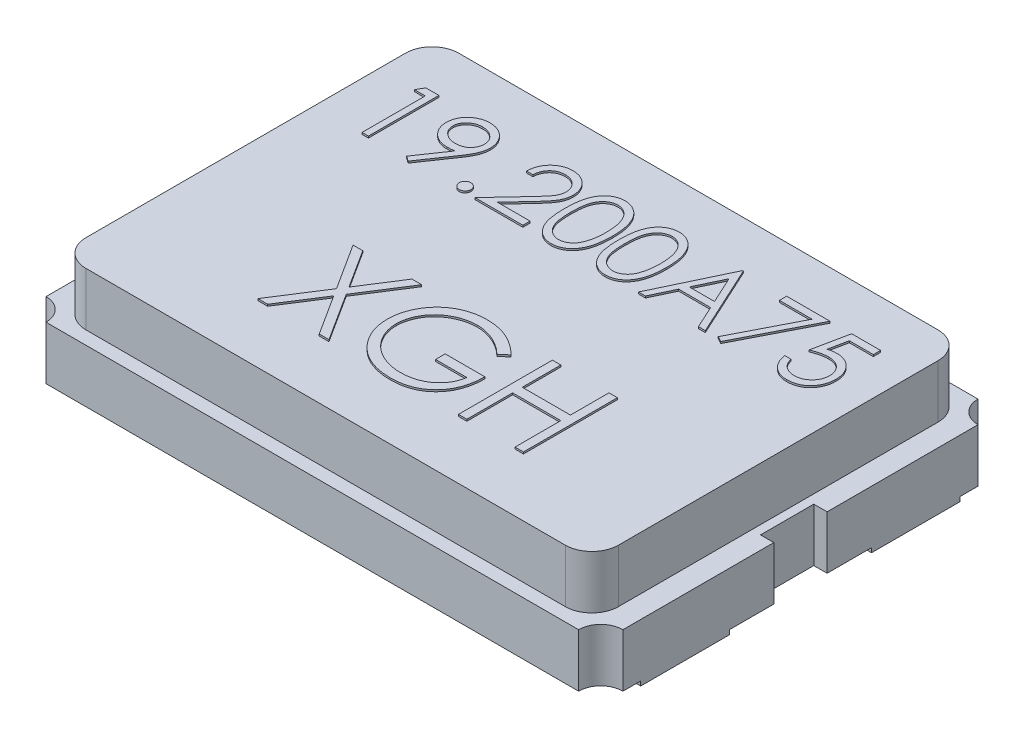
from build123d import *

# Parameters (mm, degrees)
EXTRUDE1_DEPTH = 0.6
EXTRUDE2_DEPTH = 0.6
SKETCH3_W      = 1
SKETCH3_H      = 1
EXTRUDE3_DEPTH = 0.05
EXTRUDE4_DEPTH = 0.02
EXTRUDE5_DEPTH = 0.02


with BuildPart() as part:
    # Sketch1 → Extrude1 (new body)
    with BuildSketch(Plane(origin=(0, 0, 0), x_dir=(1, 0, 0), z_dir=(0, 1, 0))):
        with BuildLine():
            Line((-3.25, 2), (-3.25, 0.3))
            Line((-3.25, 0.3), (-3.1, 0.3))
            Line((-3.1, 0.3), (-3.1, -0.3))
            Line((-3.1, -0.3), (-3.25, -0.3))
            Line((-3.25, -0.3), (-3.25, -2))
            ThreePointArc((-3.25, -2), (-3.073223305, -2.073223305), (-3, -2.25))
            Line((-3, -2.25), (3, -2.25))
            ThreePointArc((3, -2.25), (3.073223305, -2.073223305), (3.25, -2))
            Line((3.25, -2), (3.25, -0.3))
            Line((3.25, -0.3), (3.1, -0.3))
            Line((3.1, -0.3), (3.1, 0.3))
            Line((3.1, 0.3), (3.25, 0.3))
            Line((3.25, 0.3), (3.25, 2))
            ThreePointArc((3.25, 2), (3.073223305, 2.073223305), (3, 2.25))
            Line((3, 2.25), (-3, 2.25))
            ThreePointArc((-3, 2.25), (-3.073223305, 2.073223305), (-3.25, 2))
        make_face()
    extrude(amount=EXTRUDE1_DEPTH)

    # Sketch2 → Extrude2 (add)
    with BuildSketch(Plane(origin=(0, 0.6, 0), x_dir=(1, 0, 0), z_dir=(0, 1, 0))):
        with BuildLine():
            Line((-2.7, 2.1), (2.7, 2.1))
            ThreePointArc((2.7, 2.1), (2.912132034, 2.012132034), (3, 1.8))
            Line((3, 1.8), (3, -1.8))
            ThreePointArc((3, -1.8), (2.912132034, -2.012132034), (2.7, -2.1))
            Line((2.7, -2.1), (-2.7, -2.1))
            ThreePointArc((-2.7, -2.1), (-2.912132034, -2.012132034), (-3, -1.8))
            Line((-3, -1.8), (-3, 1.8))
            ThreePointArc((-3, 1.8), (-2.912132034, 2.012132034), (-2.7, 2.1))
        make_face()
    extrude(amount=EXTRUDE2_DEPTH)

    # Sketch3 → Extrude3 (add)
    with BuildSketch(Plane.XZ):
        with Locations((-2.75, 1.3)):
            Rectangle(SKETCH3_W, SKETCH3_H)
        with Locations((-2.75, -1.3)):
            Rectangle(SKETCH3_W, SKETCH3_H)
        with Locations((2.75, 1.3)):
            Rectangle(SKETCH3_W, SKETCH3_H)
        with Locations((2.75, -1.3)):
            Rectangle(SKETCH3_W, SKETCH3_H)
    extrude(amount=EXTRUDE3_DEPTH)

    # Sketch4 → Extrude4 (add)
    with BuildSketch(Plane(origin=(0, 1.2, 0), x_dir=(1, 0, 0), z_dir=(0, 1, 0))):
        Polygon((-2.526616546, 1.555911653), (-2.379855478, 1.555911653), (-2.379855478, 0.762161653), (-2.451089453, 0.762161653), (-2.451089453, 1.474501397), (-2.573204837, 1.474501397), align=None)
        with BuildLine():
            Line((-1.911746504, 0.741809089), (-1.968670082, 0.781401186))
            Line((-1.968670082, 0.781401186), (-1.747971965, 1.104021128))
            add(Edge.make_bspline(
                [(-1.747971965, 1.104021128), (-1.762053257, 1.10229913), (-1.789780105, 1.098908419), (-1.817705841, 1.098285517), (-1.831449279, 1.097978961)],
                knots=[0, 0, 0, 0, 4.2529e-05, 8.3742e-05, 8.3742e-05, 8.3742e-05, 8.3742e-05], degree=3))
            add(Edge.make_bspline(
                [(-1.831449279, 1.097978961), (-1.83978185, 1.098192384), (-1.856137959, 1.098611314), (-1.880184423, 1.101931867), (-1.903290613, 1.107045914), (-1.925395271, 1.11467697), (-1.94658148, 1.124160743), (-1.96680299, 1.135921173), (-1.986032579, 1.149756528), (-2.004063724, 1.165593653), (-2.020462993, 1.18298314), (-2.035073277, 1.20138808), (-2.047215641, 1.221022274), (-2.057302295, 1.241485199), (-2.06495188, 1.263070969), (-2.070522313, 1.285533958), (-2.073951847, 1.309031598), (-2.074359856, 1.32502569), (-2.074567017, 1.333146479)],
                knots=[0, 0, 0, 0, 2.4988e-05, 4.905e-05, 7.2695e-05, 9.5876e-05, 0.000119076, 0.00014223, 0.000165926, 0.000190038, 0.000214108, 0.000237551, 0.000260406, 0.000283233, 0.000305865, 0.000328965, 0.000352576, 0.000376929, 0.000376929, 0.000376929, 0.000376929], degree=3))
            add(Edge.make_bspline(
                [(-2.074567017, 1.333146479), (-2.074173672, 1.34425187), (-2.073401615, 1.366049499), (-2.067188023, 1.397897872), (-2.056968982, 1.428011963), (-2.042720404, 1.456312596), (-2.024773779, 1.482392668), (-2.00320451, 1.50588962), (-1.978143789, 1.526469256), (-1.95016251, 1.544159467), (-1.91991995, 1.558386868), (-1.888245093, 1.568873281), (-1.855380641, 1.575041568), (-1.833117616, 1.57585479), (-1.821909014, 1.576264217)],
                knots=[0, 0, 0, 0, 3.3296e-05, 6.5354e-05, 9.6931e-05, 0.000128432, 0.0001601, 0.00019161, 0.000223797, 0.000257102, 0.000290674, 0.00032381, 0.000356961, 0.000390575, 0.000390575, 0.000390575, 0.000390575], degree=3))
            add(Edge.make_bspline(
                [(-1.821909014, 1.576264217), (-1.810912533, 1.575849163), (-1.789184524, 1.575029053), (-1.75723291, 1.569022867), (-1.726630215, 1.558899908), (-1.697546084, 1.54491073), (-1.670617681, 1.527375453), (-1.646402453, 1.506480659), (-1.625453, 1.482213334), (-1.607803656, 1.455160408), (-1.593636343, 1.426093968), (-1.583414593, 1.395753686), (-1.577122279, 1.364357761), (-1.576329362, 1.343086515), (-1.575929196, 1.332351457)],
                knots=[0, 0, 0, 0, 3.2979e-05, 6.5163e-05, 9.7142e-05, 0.000129429, 0.000161712, 0.000193274, 0.000225059, 0.000257562, 0.000289919, 0.000321797, 0.000353386, 0.000385572, 0.000385572, 0.000385572, 0.000385572], degree=3))
            add(Edge.make_bspline(
                [(-1.575929196, 1.332351457), (-1.576196443, 1.324018495), (-1.576738485, 1.307117167), (-1.58053404, 1.281438143), (-1.586979332, 1.255255454), (-1.594293557, 1.233093592), (-1.601353888, 1.214790068), (-1.607998966, 1.200332121), (-1.615372258, 1.185114513), (-1.623971692, 1.169296813), (-1.633215999, 1.152677381), (-1.643661585, 1.135422908), (-1.65507017, 1.11751024), (-1.663195838, 1.105434561), (-1.66735673, 1.099250996)],
                knots=[0, 0, 0, 0, 2.4996e-05, 5.0698e-05, 7.7694e-05, 0.000105802, 0.000120654, 0.000136524, 0.00015352, 0.000171375, 0.000190526, 0.000210569, 0.000231873, 0.000254232, 0.000254232, 0.000254232, 0.000254232], degree=3))
            Line((-1.66735673, 1.099250996), (-1.911746504, 0.741809089))
        make_face()
        with BuildLine():
            add(Edge.make_bspline(
                [(-1.818251913, 1.179389217), (-1.811939556, 1.179561662), (-1.799651543, 1.179897352), (-1.781649906, 1.181940519), (-1.764658167, 1.185563191), (-1.748630937, 1.190761054), (-1.733407515, 1.197033192), (-1.719229705, 1.205018767), (-1.706085641, 1.21454754), (-1.693887308, 1.225254097), (-1.683055115, 1.23714914), (-1.673406963, 1.249599019), (-1.665206263, 1.262658386), (-1.65872852, 1.276490787), (-1.653402554, 1.290759511), (-1.64972454, 1.305694338), (-1.647687022, 1.321217457), (-1.647339683, 1.331762689), (-1.647163171, 1.337121589)],
                knots=[0, 0, 0, 0, 1.8938e-05, 3.6866e-05, 5.4268e-05, 7.0963e-05, 8.7353e-05, 0.000103585, 0.000119647, 0.000135981, 0.000152186, 0.000167833, 0.000183187, 0.000198336, 0.000213578, 0.000228811, 0.000244373, 0.000260452, 0.000260452, 0.000260452, 0.000260452], degree=3))
            add(Edge.make_bspline(
                [(-1.647163171, 1.337121589), (-1.647315042, 1.342482727), (-1.647614323, 1.353047508), (-1.650015372, 1.36859361), (-1.654239306, 1.383491903), (-1.659906791, 1.397823951), (-1.667372631, 1.411471999), (-1.676331457, 1.424607399), (-1.686975066, 1.437146863), (-1.699222077, 1.448795481), (-1.712428841, 1.459533308), (-1.726503276, 1.469009793), (-1.741329373, 1.4769521), (-1.756816681, 1.483505974), (-1.772997467, 1.488620394), (-1.789862157, 1.492298261), (-1.807495973, 1.494332927), (-1.819466014, 1.494678071), (-1.825566116, 1.494853961)],
                knots=[0, 0, 0, 0, 1.6079e-05, 3.1686e-05, 4.704e-05, 6.2453e-05, 7.7821e-05, 9.3609e-05, 0.00011008, 0.000127061, 0.000144245, 0.000161091, 0.00017788, 0.000194625, 0.000211471, 0.000228718, 0.00024633, 0.000264633, 0.000264633, 0.000264633, 0.000264633], degree=3))
            add(Edge.make_bspline(
                [(-1.825566116, 1.494853961), (-1.831613165, 1.494677787), (-1.843477425, 1.494332134), (-1.860954475, 1.492302129), (-1.877705133, 1.48859566), (-1.893839036, 1.483508343), (-1.909325884, 1.476951611), (-1.924151281, 1.469009377), (-1.938229008, 1.45953549), (-1.951423111, 1.448787032), (-1.963691747, 1.437201084), (-1.974152358, 1.424552467), (-1.983131687, 1.411478832), (-1.990587268, 1.397822135), (-1.996257482, 1.383492388), (-2.000480686, 1.368593479), (-2.002881931, 1.353047542), (-2.003181185, 1.342482739), (-2.003333043, 1.337121589)],
                knots=[0, 0, 0, 0, 1.8144e-05, 3.5598e-05, 5.269e-05, 6.9536e-05, 8.628e-05, 0.000103069, 0.000119916, 0.0001371, 0.000154081, 0.000170449, 0.000186238, 0.000201605, 0.000217018, 0.000232372, 0.000247979, 0.000264058, 0.000264058, 0.000264058, 0.000264058], degree=3))
            add(Edge.make_bspline(
                [(-2.003333043, 1.337121589), (-2.003195627, 1.331758515), (-2.002924619, 1.321181553), (-2.000310281, 1.305640746), (-1.995938242, 1.290743602), (-1.990082773, 1.27634527), (-1.982371699, 1.262585759), (-1.972909326, 1.249530304), (-1.961818247, 1.237030907), (-1.949246724, 1.225281772), (-1.935488051, 1.214497618), (-1.920793075, 1.20507912), (-1.905414773, 1.197125191), (-1.88929901, 1.190743127), (-1.872565218, 1.185615125), (-1.855063001, 1.181947196), (-1.83685024, 1.17991695), (-1.824510833, 1.179566816), (-1.818251913, 1.179389217)],
                knots=[0, 0, 0, 0, 1.6079e-05, 3.1711e-05, 4.7109e-05, 6.2581e-05, 7.8242e-05, 9.4304e-05, 0.000110863, 0.000128299, 0.000145857, 0.000163235, 0.000180587, 0.000197712, 0.000215165, 0.000233034, 0.000251278, 0.000270058, 0.000270058, 0.000270058, 0.000270058], degree=3))
        make_face(mode=Mode.SUBTRACT)
        with BuildLine():
            add(Edge.make_bspline(
                [(-1.34696285, 0.884277038), (-1.342542749, 0.884014382), (-1.333877656, 0.883499476), (-1.321350211, 0.879966909), (-1.310012136, 0.87369432), (-1.299912859, 0.865334369), (-1.291588355, 0.855198031), (-1.285092225, 0.843950387), (-1.28159043, 0.831318062), (-1.281079275, 0.822602761), (-1.280817017, 0.818131205)],
                knots=[0, 0, 0, 0, 1.3259e-05, 2.5992e-05, 3.8656e-05, 5.1869e-05, 6.5082e-05, 7.7823e-05, 9.0556e-05, 0.000103973, 0.000103973, 0.000103973, 0.000103973], degree=3))
            add(Edge.make_bspline(
                [(-1.280817017, 0.818131205), (-1.281088162, 0.813767092), (-1.281622856, 0.805161127), (-1.285084198, 0.792624081), (-1.291637863, 0.781369408), (-1.299855442, 0.77109553), (-1.310014633, 0.762717868), (-1.321377016, 0.756498646), (-1.333848248, 0.752713143), (-1.342537842, 0.752230929), (-1.34696285, 0.751985371)],
                knots=[0, 0, 0, 0, 1.31e-05, 2.5834e-05, 3.8575e-05, 5.191e-05, 6.5123e-05, 7.7788e-05, 9.0565e-05, 0.000103824, 0.000103824, 0.000103824, 0.000103824], degree=3))
            add(Edge.make_bspline(
                [(-1.34696285, 0.751985371), (-1.351391047, 0.752222044), (-1.360036046, 0.752684092), (-1.372460727, 0.756576371), (-1.383892307, 0.762659549), (-1.394049521, 0.771111151), (-1.402335924, 0.781316541), (-1.408600966, 0.792701591), (-1.412363375, 0.805125239), (-1.412858192, 0.813760024), (-1.413108684, 0.818131205)],
                knots=[0, 0, 0, 0, 1.3259e-05, 2.5884e-05, 3.8689e-05, 5.1901e-05, 6.5237e-05, 7.7901e-05, 9.0679e-05, 0.00010378, 0.00010378, 0.00010378, 0.00010378], degree=3))
            add(Edge.make_bspline(
                [(-1.413108684, 0.818131205), (-1.412867815, 0.822610082), (-1.412397548, 0.83135454), (-1.408593068, 0.843872909), (-1.402384534, 0.855250394), (-1.393992239, 0.865318904), (-1.383894765, 0.873752453), (-1.372488304, 0.879890362), (-1.360006122, 0.883528098), (-1.351386011, 0.884023062), (-1.34696285, 0.884277038)],
                knots=[0, 0, 0, 0, 1.3417e-05, 2.6195e-05, 3.8859e-05, 5.2072e-05, 6.5285e-05, 7.8089e-05, 9.067e-05, 0.000103928, 0.000103928, 0.000103928, 0.000103928], degree=3))
        make_face()
        with BuildLine():
            Line((-1.077291376, 1.311680884), (-1.14852535, 1.311680884))
            add(Edge.make_bspline(
                [(-1.14852535, 1.311680884), (-1.148061085, 1.321131246), (-1.147149281, 1.339691506), (-1.142879294, 1.366752463), (-1.136769488, 1.392618462), (-1.12813089, 1.417081817), (-1.117402502, 1.440358833), (-1.104536943, 1.46235705), (-1.089298337, 1.482992552), (-1.072015739, 1.50207404), (-1.053244994, 1.519579078), (-1.032991682, 1.534695535), (-1.011708971, 1.547467578), (-0.989461429, 1.558144932), (-0.965998051, 1.566159504), (-0.94153176, 1.572106197), (-0.915955063, 1.575684047), (-0.898528843, 1.576068627), (-0.889666176, 1.576264217)],
                knots=[0, 0, 0, 0, 2.8367e-05, 5.5712e-05, 8.2052e-05, 0.000108001, 0.000133399, 0.000158842, 0.000184315, 0.00021021, 0.000235977, 0.000261195, 0.000285874, 0.00031034, 0.000335081, 0.00036011, 0.00038579, 0.000412367, 0.000412367, 0.000412367, 0.000412367], degree=3))
            add(Edge.make_bspline(
                [(-0.889666176, 1.576264217), (-0.880962577, 1.57606046), (-0.863860316, 1.575660085), (-0.838899823, 1.57222178), (-0.81513783, 1.566836619), (-0.792620782, 1.559281159), (-0.771528336, 1.54912469), (-0.751702038, 1.536924177), (-0.732905854, 1.522813608), (-0.715986101, 1.50620069), (-0.700449448, 1.488465506), (-0.687045901, 1.469531642), (-0.675567558, 1.449976072), (-0.665999995, 1.429649676), (-0.658956906, 1.408361068), (-0.653609706, 1.386420185), (-0.650587239, 1.363599915), (-0.650123366, 1.348154321), (-0.64988753, 1.340301677)],
                knots=[0, 0, 0, 0, 2.61e-05, 5.1286e-05, 7.5432e-05, 9.9115e-05, 0.000122372, 0.000145497, 0.000168871, 0.000192711, 0.000216494, 0.000239525, 0.000262187, 0.000284454, 0.000306779, 0.00032934, 0.00035212, 0.000375679, 0.000375679, 0.000375679, 0.000375679], degree=3))
            add(Edge.make_bspline(
                [(-0.64988753, 1.340301677), (-0.650271538, 1.329246365), (-0.651032814, 1.307329745), (-0.657544825, 1.275122803), (-0.667715373, 1.243918581), (-0.679961202, 1.218804943), (-0.692314774, 1.198568061), (-0.70344712, 1.181906408), (-0.716479318, 1.163966418), (-0.731601049, 1.144808165), (-0.748499504, 1.124281585), (-0.767327744, 1.102399078), (-0.788220034, 1.07938673), (-0.802883658, 1.06366921), (-0.810481981, 1.055524784)],
                knots=[0, 0, 0, 0, 3.3137e-05, 6.5693e-05, 9.8175e-05, 0.000131386, 0.00014922, 0.000169286, 0.000191485, 0.000215723, 0.000242495, 0.000271245, 0.000302316, 0.000335732, 0.000335732, 0.000335732, 0.000335732], degree=3))
            Line((-0.810481981, 1.055524784), (-1.009078485, 0.84357191))
            Line((-1.009078485, 0.84357191), (-0.639711248, 0.84357191))
            Line((-0.639711248, 0.84357191), (-0.639711248, 0.762161653))
            Line((-0.639711248, 0.762161653), (-1.179054196, 0.762161653))
            Line((-1.179054196, 0.762161653), (-0.871221664, 1.090664758))
            add(Edge.make_bspline(
                [(-0.871221664, 1.090664758), (-0.863726876, 1.098488481), (-0.849330921, 1.113516252), (-0.828969515, 1.135456174), (-0.810681744, 1.155810087), (-0.794349228, 1.174539537), (-0.780326273, 1.191918481), (-0.767882034, 1.207384066), (-0.757911267, 1.221615879), (-0.747090096, 1.238112411), (-0.736609426, 1.258253776), (-0.727603231, 1.282867666), (-0.722111649, 1.308205811), (-0.721452874, 1.325328594), (-0.721121504, 1.333941501)],
                knots=[0, 0, 0, 0, 3.2503e-05, 6.2431e-05, 8.9791e-05, 0.000114592, 0.000136967, 0.000156784, 0.000174122, 0.000189073, 0.000215956, 0.000242011, 0.000267521, 0.000293339, 0.000293339, 0.000293339, 0.000293339], degree=3))
            add(Edge.make_bspline(
                [(-0.721121504, 1.333941501), (-0.721265681, 1.339357461), (-0.721549827, 1.350031278), (-0.724057555, 1.365680798), (-0.727847259, 1.380776747), (-0.733277701, 1.395365559), (-0.740445659, 1.409300555), (-0.749170872, 1.422598698), (-0.759237904, 1.435454946), (-0.770883638, 1.447509354), (-0.783676965, 1.458549556), (-0.797192089, 1.468329483), (-0.811490952, 1.476502638), (-0.826513266, 1.483202681), (-0.842217149, 1.488458527), (-0.858632975, 1.492100383), (-0.875715386, 1.494386946), (-0.887379768, 1.494696321), (-0.893323277, 1.494853961)],
                knots=[0, 0, 0, 0, 1.6238e-05, 3.2002e-05, 4.7428e-05, 6.2874e-05, 7.859e-05, 9.4334e-05, 0.000110526, 0.000127506, 0.000144529, 0.000161164, 0.000177474, 0.000193845, 0.000210438, 0.000227064, 0.000244222, 0.000262048, 0.000262048, 0.000262048, 0.000262048], degree=3))
            add(Edge.make_bspline(
                [(-0.893323277, 1.494853961), (-0.899530591, 1.494691802), (-0.91172073, 1.494373348), (-0.92961844, 1.492145708), (-0.946692178, 1.488302634), (-0.962984896, 1.483046495), (-0.978524159, 1.476365717), (-0.993234397, 1.468044554), (-1.007082588, 1.458115083), (-1.020094764, 1.446857314), (-1.032083559, 1.434323411), (-1.042617047, 1.420351152), (-1.051820922, 1.405195649), (-1.05985123, 1.388897795), (-1.06637261, 1.371309706), (-1.071355807, 1.352493816), (-1.075298895, 1.332531824), (-1.076616185, 1.318746635), (-1.077291376, 1.311680884)],
                knots=[0, 0, 0, 0, 1.862e-05, 3.6568e-05, 5.4004e-05, 7.105e-05, 8.7857e-05, 0.00010466, 0.000121647, 0.000138894, 0.000156214, 0.000173578, 0.000191276, 0.000209338, 0.000228004, 0.000247444, 0.000267683, 0.000288965, 0.000288965, 0.000288965, 0.000288965], degree=3))
        make_face()
        with BuildLine():
            add(Edge.make_bspline(
                [(-0.568477273, 1.158718644), (-0.568402884, 1.171440731), (-0.56825838, 1.196153566), (-0.566650828, 1.232163655), (-0.563980348, 1.26594572), (-0.560320623, 1.29750138), (-0.555867009, 1.32683878), (-0.549921711, 1.35387952), (-0.543160594, 1.378748752), (-0.535324592, 1.401527574), (-0.526482719, 1.422522874), (-0.516859235, 1.442122875), (-0.506072219, 1.46029792), (-0.494738169, 1.477338098), (-0.482398288, 1.492964472), (-0.469403741, 1.507397718), (-0.455247352, 1.520304263), (-0.440410348, 1.532062264), (-0.4247584, 1.542369555), (-0.408737652, 1.551448408), (-0.392237834, 1.55920445), (-0.375213896, 1.565302816), (-0.357818851, 1.570339919), (-0.339991892, 1.573784555), (-0.321703582, 1.575951926), (-0.30935931, 1.576159133), (-0.303098918, 1.576264217)],
                knots=[0, 0, 0, 0, 3.8164e-05, 7.4134e-05, 0.00010811, 0.000139804, 0.000169422, 0.000197086, 0.000222816, 0.000246701, 0.000269292, 0.000291122, 0.000312148, 0.000332654, 0.000352471, 0.000371831, 0.000390848, 0.00040987, 0.000428569, 0.000447009, 0.000465077, 0.000483186, 0.000501205, 0.000519353, 0.000537597, 0.000556371, 0.000556371, 0.000556371, 0.000556371], degree=3))
            add(Edge.make_bspline(
                [(-0.303098918, 1.576264217), (-0.296786229, 1.576153588), (-0.284232277, 1.575933581), (-0.265672049, 1.573819044), (-0.247540603, 1.570310414), (-0.22991524, 1.56533905), (-0.21265118, 1.559171459), (-0.195883459, 1.551440988), (-0.179507925, 1.542442388), (-0.163784806, 1.531868758), (-0.148541492, 1.520079921), (-0.1341524, 1.506753387), (-0.120616221, 1.492023718), (-0.107763072, 1.47604851), (-0.095957606, 1.458521357), (-0.08471506, 1.439747103), (-0.074652116, 1.419397425), (-0.064960502, 1.397811855), (-0.056595061, 1.374393132), (-0.049050751, 1.349273267), (-0.042954985, 1.322155549), (-0.037877418, 1.293182258), (-0.033943844, 1.262246989), (-0.031078941, 1.229416057), (-0.02956558, 1.194667861), (-0.029280579, 1.170910278), (-0.029134325, 1.158718644)],
                knots=[0, 0, 0, 0, 1.8932e-05, 3.765e-05, 5.5955e-05, 7.428e-05, 9.2538e-05, 0.000110895, 0.000129613, 0.000148532, 0.000167679, 0.000187371, 0.000207287, 0.000227649, 0.000248819, 0.000270634, 0.000293247, 0.000316882, 0.000341579, 0.00036779, 0.000395523, 0.000424906, 0.000456008, 0.000489046, 0.000523745, 0.000560322, 0.000560322, 0.000560322, 0.000560322], degree=3))
            add(Edge.make_bspline(
                [(-0.029134325, 1.158718644), (-0.029282095, 1.146580187), (-0.029570019, 1.122928897), (-0.031061975, 1.088337051), (-0.034000808, 1.055680352), (-0.037677002, 1.024880479), (-0.042768559, 0.996065626), (-0.049029017, 0.969136081), (-0.055980072, 0.943975551), (-0.064560463, 0.920790156), (-0.07395182, 0.899256462), (-0.084169695, 0.879148019), (-0.095116602, 0.860287092), (-0.107042978, 0.84282465), (-0.119755092, 0.82663699), (-0.133525019, 0.81200985), (-0.147964598, 0.798590787), (-0.163252771, 0.78665015), (-0.179221105, 0.776198775), (-0.195540395, 0.766852063), (-0.212500198, 0.759315362), (-0.229716171, 0.752844022), (-0.247434569, 0.747899991), (-0.265633304, 0.744481456), (-0.284219807, 0.742083912), (-0.296784091, 0.741901014), (-0.303098918, 0.741809089)],
                knots=[0, 0, 0, 0, 3.6418e-05, 7.0958e-05, 0.000103838, 0.000134762, 0.000163988, 0.000191566, 0.000217688, 0.000242235, 0.000265661, 0.000288132, 0.000309867, 0.000331036, 0.000351523, 0.000371548, 0.000391239, 0.00041061, 0.000429661, 0.000448457, 0.000466959, 0.000485271, 0.000503596, 0.000522057, 0.000540793, 0.000559725, 0.000559725, 0.000559725, 0.000559725], degree=3))
            add(Edge.make_bspline(
                [(-0.303098918, 0.741809089), (-0.309359137, 0.741914852), (-0.321703066, 0.742123395), (-0.339993884, 0.744280974), (-0.357747224, 0.747749775), (-0.375050691, 0.752606755), (-0.391993062, 0.758551906), (-0.40834347, 0.766297473), (-0.424283712, 0.775217878), (-0.439771261, 0.78537684), (-0.454515091, 0.797015864), (-0.468598167, 0.809889194), (-0.481666698, 0.824318075), (-0.493830145, 0.840074675), (-0.50539034, 0.857014036), (-0.51602418, 0.875367434), (-0.52586007, 0.895062098), (-0.534850648, 0.916225267), (-0.542821862, 0.93916576), (-0.549863039, 0.96414602), (-0.5554225, 0.99138653), (-0.560181134, 1.020668504), (-0.564019343, 1.052117771), (-0.566639698, 1.085751402), (-0.568259247, 1.121548441), (-0.568403272, 1.146102479), (-0.568477273, 1.158718644)],
                knots=[0, 0, 0, 0, 1.8773e-05, 3.7017e-05, 5.5166e-05, 7.2989e-05, 9.0894e-05, 0.000108962, 0.000127186, 0.000145664, 0.000164463, 0.00018348, 0.00020284, 0.000222782, 0.000243157, 0.000264319, 0.000286363, 0.000309162, 0.00033325, 0.000359175, 0.000386961, 0.000416604, 0.00044816, 0.000481977, 0.000517788, 0.000555634, 0.000555634, 0.000555634, 0.000555634], degree=3))
        make_face()
        with BuildLine():
            add(Edge.make_bspline(
                [(-0.497243299, 1.159036653), (-0.49721621, 1.148434716), (-0.497163636, 1.127858438), (-0.495790176, 1.09795827), (-0.493919141, 1.070070356), (-0.491505847, 1.044159286), (-0.487921964, 1.020312766), (-0.483906318, 0.998366784), (-0.479019519, 0.978437482), (-0.473237613, 0.960388103), (-0.466651961, 0.943912333), (-0.459461524, 0.928581343), (-0.451737038, 0.914214029), (-0.44309216, 0.900939442), (-0.433677136, 0.888714294), (-0.423704629, 0.877322206), (-0.412802454, 0.86716289), (-0.397720355, 0.854978407), (-0.377809369, 0.842387461), (-0.35272223, 0.831423258), (-0.326943849, 0.824532951), (-0.309447048, 0.823656706), (-0.300713852, 0.823219346)],
                knots=[0, 0, 0, 0, 3.1802e-05, 6.1722e-05, 8.9772e-05, 0.000115656, 0.000139762, 0.000162091, 0.000182568, 0.000201274, 0.000218901, 0.00023576, 0.000252053, 0.000267798, 0.000283222, 0.000298315, 0.000313163, 0.000327864, 0.000356449, 0.000383508, 0.000409771, 0.000435943, 0.000435943, 0.000435943, 0.000435943], degree=3))
            add(Edge.make_bspline(
                [(-0.300713852, 0.823219346), (-0.291924166, 0.823581699), (-0.274362941, 0.824305659), (-0.248705812, 0.831290373), (-0.223797876, 0.841829), (-0.204277989, 0.85429031), (-0.189427484, 0.866157627), (-0.178787381, 0.876275592), (-0.169021523, 0.887604869), (-0.159759124, 0.899828459), (-0.151263941, 0.913179898), (-0.143538908, 0.927594982), (-0.136489649, 0.943113742), (-0.13247349, 0.953947236), (-0.130420132, 0.959486122)],
                knots=[0, 0, 0, 0, 2.6317e-05, 5.258e-05, 7.922e-05, 0.000107233, 0.00012171, 0.000136218, 0.000151206, 0.000166534, 0.000182192, 0.000198626, 0.000215562, 0.000233279, 0.000233279, 0.000233279, 0.000233279], degree=3))
            add(Edge.make_bspline(
                [(-0.130420132, 0.959486122), (-0.128027142, 0.966568581), (-0.123168345, 0.98094901), (-0.116906389, 1.003256481), (-0.111974844, 1.026661393), (-0.107538152, 1.051023875), (-0.104509869, 1.076523593), (-0.102072419, 1.103081648), (-0.100636709, 1.130718064), (-0.100458739, 1.149494785), (-0.100368299, 1.159036653)],
                knots=[0, 0, 0, 0, 2.2426e-05, 4.5534e-05, 6.9455e-05, 9.4159e-05, 0.000119797, 0.000146458, 0.000174162, 0.000202787, 0.000202787, 0.000202787, 0.000202787], degree=3))
            add(Edge.make_bspline(
                [(-0.100368299, 1.159036653), (-0.100493074, 1.168576978), (-0.100737161, 1.187239892), (-0.101670154, 1.214571694), (-0.104079429, 1.240531346), (-0.106755301, 1.265230686), (-0.110700742, 1.288532987), (-0.114954745, 1.310633324), (-0.12067002, 1.331257903), (-0.12677504, 1.350729629), (-0.133762398, 1.368827278), (-0.141454002, 1.385635226), (-0.149668579, 1.401234618), (-0.158590837, 1.415582657), (-0.168114858, 1.428743609), (-0.178492017, 1.440453597), (-0.189310687, 1.451075552), (-0.20446387, 1.463200099), (-0.224301789, 1.475562573), (-0.248986427, 1.486939451), (-0.274674591, 1.49347276), (-0.292040357, 1.494393893), (-0.300713852, 1.494853961)],
                knots=[0, 0, 0, 0, 2.8625e-05, 5.5996e-05, 8.2009e-05, 0.000106821, 0.000130504, 0.000152893, 0.0001743, 0.000194666, 0.000214095, 0.000232453, 0.000250093, 0.000266947, 0.000283103, 0.000298764, 0.000313832, 0.000328533, 0.000356899, 0.000383731, 0.000409801, 0.000435814, 0.000435814, 0.000435814, 0.000435814], degree=3))
            add(Edge.make_bspline(
                [(-0.300713852, 1.494853961), (-0.309492861, 1.494393258), (-0.327066873, 1.493471012), (-0.353022034, 1.486963792), (-0.377901414, 1.475621566), (-0.397686874, 1.463159153), (-0.412850626, 1.451289572), (-0.423528308, 1.440996572), (-0.433540029, 1.429737511), (-0.442762883, 1.417399934), (-0.451400988, 1.404140824), (-0.459334182, 1.389855872), (-0.466481862, 1.374472688), (-0.473077819, 1.358004317), (-0.478877362, 1.339956496), (-0.483661172, 1.320051742), (-0.488080557, 1.298175563), (-0.491209127, 1.274199889), (-0.493990372, 1.248282329), (-0.495777749, 1.220324795), (-0.49716823, 1.19037448), (-0.497217775, 1.169691813), (-0.497243299, 1.159036653)],
                knots=[0, 0, 0, 0, 2.633e-05, 5.2708e-05, 7.9685e-05, 0.000108051, 0.000122653, 0.000137386, 0.000152479, 0.000167807, 0.000183551, 0.000199922, 0.00021678, 0.000234407, 0.000253113, 0.000273591, 0.000295793, 0.000320034, 0.000346092, 0.000373983, 0.000404062, 0.000436024, 0.000436024, 0.000436024, 0.000436024], degree=3))
        make_face(mode=Mode.SUBTRACT)
        with BuildLine():
            add(Edge.make_bspline(
                [(0.04209965, 1.158718644), (0.04217404, 1.171440731), (0.042318543, 1.196153566), (0.043926095, 1.232163655), (0.046596575, 1.26594572), (0.050256301, 1.29750138), (0.054709914, 1.32683878), (0.060655212, 1.35387952), (0.067416329, 1.378748752), (0.075252331, 1.401527574), (0.084094204, 1.422522874), (0.093717688, 1.442122875), (0.104504704, 1.46029792), (0.115838754, 1.477338098), (0.128178635, 1.492964472), (0.141173182, 1.507397718), (0.155329572, 1.520304263), (0.170166575, 1.532062264), (0.185818523, 1.542369555), (0.201839271, 1.551448408), (0.21833909, 1.55920445), (0.235363027, 1.565302816), (0.252758072, 1.570339919), (0.270585032, 1.573784555), (0.288873341, 1.575951926), (0.301217613, 1.576159133), (0.307478005, 1.576264217)],
                knots=[0, 0, 0, 0, 3.8164e-05, 7.4134e-05, 0.00010811, 0.000139804, 0.000169422, 0.000197086, 0.000222816, 0.000246701, 0.000269292, 0.000291122, 0.000312148, 0.000332654, 0.000352471, 0.000371831, 0.000390848, 0.00040987, 0.000428569, 0.000447009, 0.000465077, 0.000483186, 0.000501205, 0.000519353, 0.000537597, 0.000556371, 0.000556371, 0.000556371, 0.000556371], degree=3))
            add(Edge.make_bspline(
                [(0.307478005, 1.576264217), (0.313790694, 1.576153588), (0.326344646, 1.575933581), (0.344904874, 1.573819044), (0.36303632, 1.570310414), (0.380661683, 1.56533905), (0.397925743, 1.559171459), (0.414693464, 1.551440988), (0.431068998, 1.542442388), (0.446792117, 1.531868758), (0.462035432, 1.520079921), (0.476424523, 1.506753387), (0.489960702, 1.492023718), (0.502813851, 1.47604851), (0.514619317, 1.458521357), (0.525861863, 1.439747103), (0.535924807, 1.419397425), (0.545616421, 1.397811855), (0.553981863, 1.374393132), (0.561526172, 1.349273267), (0.567621938, 1.322155549), (0.572699505, 1.293182258), (0.57663308, 1.262246989), (0.579497982, 1.229416057), (0.581011343, 1.194667861), (0.581296345, 1.170910278), (0.581442598, 1.158718644)],
                knots=[0, 0, 0, 0, 1.8932e-05, 3.765e-05, 5.5955e-05, 7.428e-05, 9.2538e-05, 0.000110895, 0.000129613, 0.000148532, 0.000167679, 0.000187371, 0.000207287, 0.000227649, 0.000248819, 0.000270634, 0.000293247, 0.000316882, 0.000341579, 0.00036779, 0.000395523, 0.000424906, 0.000456008, 0.000489046, 0.000523745, 0.000560322, 0.000560322, 0.000560322, 0.000560322], degree=3))
            add(Edge.make_bspline(
                [(0.581442598, 1.158718644), (0.581294828, 1.146580187), (0.581006904, 1.122928897), (0.579514948, 1.088337051), (0.576576115, 1.055680352), (0.572899922, 1.024880479), (0.567808364, 0.996065626), (0.561547906, 0.969136081), (0.554596851, 0.943975551), (0.54601646, 0.920790156), (0.536625103, 0.899256462), (0.526407228, 0.879148019), (0.515460321, 0.860287092), (0.503533945, 0.84282465), (0.490821832, 0.82663699), (0.477051904, 0.81200985), (0.462612325, 0.798590787), (0.447324152, 0.78665015), (0.431355818, 0.776198775), (0.415036528, 0.766852063), (0.398076725, 0.759315362), (0.380860752, 0.752844022), (0.363142354, 0.747899991), (0.344943619, 0.744481456), (0.326357116, 0.742083912), (0.313792832, 0.741901014), (0.307478005, 0.741809089)],
                knots=[0, 0, 0, 0, 3.6418e-05, 7.0958e-05, 0.000103838, 0.000134762, 0.000163988, 0.000191566, 0.000217688, 0.000242235, 0.000265661, 0.000288132, 0.000309867, 0.000331036, 0.000351523, 0.000371548, 0.000391239, 0.00041061, 0.000429661, 0.000448457, 0.000466959, 0.000485271, 0.000503596, 0.000522057, 0.000540793, 0.000559725, 0.000559725, 0.000559725, 0.000559725], degree=3))
            add(Edge.make_bspline(
                [(0.307478005, 0.741809089), (0.301217786, 0.741914852), (0.288873857, 0.742123395), (0.270583039, 0.744280974), (0.252829699, 0.747749775), (0.235526232, 0.752606755), (0.218583861, 0.758551906), (0.202233454, 0.766297473), (0.186293211, 0.775217878), (0.170805662, 0.78537684), (0.156061832, 0.797015864), (0.141978756, 0.809889194), (0.128910225, 0.824318075), (0.116746778, 0.840074675), (0.105186583, 0.857014036), (0.094552743, 0.875367434), (0.084716853, 0.895062098), (0.075726275, 0.916225267), (0.067755061, 0.93916576), (0.060713884, 0.96414602), (0.055154423, 0.99138653), (0.050395789, 1.020668504), (0.046557581, 1.052117771), (0.043937225, 1.085751402), (0.042317676, 1.121548441), (0.042173651, 1.146102479), (0.04209965, 1.158718644)],
                knots=[0, 0, 0, 0, 1.8773e-05, 3.7017e-05, 5.5166e-05, 7.2989e-05, 9.0894e-05, 0.000108962, 0.000127186, 0.000145664, 0.000164463, 0.00018348, 0.00020284, 0.000222782, 0.000243157, 0.000264319, 0.000286363, 0.000309162, 0.00033325, 0.000359175, 0.000386961, 0.000416604, 0.00044816, 0.000481977, 0.000517788, 0.000555634, 0.000555634, 0.000555634, 0.000555634], degree=3))
        make_face()
        with BuildLine():
            add(Edge.make_bspline(
                [(0.113333624, 1.159036653), (0.113360713, 1.148434716), (0.113413287, 1.127858438), (0.114786747, 1.09795827), (0.116657782, 1.070070356), (0.119071076, 1.044159286), (0.122654959, 1.020312766), (0.126670605, 0.998366784), (0.131557404, 0.978437482), (0.13733931, 0.960388103), (0.143924962, 0.943912333), (0.151115399, 0.928581343), (0.158839885, 0.914214029), (0.167484764, 0.900939442), (0.176899787, 0.888714294), (0.186872294, 0.877322206), (0.197774469, 0.86716289), (0.212856568, 0.854978407), (0.232767554, 0.842387461), (0.257854693, 0.831423258), (0.283633074, 0.824532951), (0.301129875, 0.823656706), (0.309863071, 0.823219346)],
                knots=[0, 0, 0, 0, 3.1802e-05, 6.1722e-05, 8.9772e-05, 0.000115656, 0.000139762, 0.000162091, 0.000182568, 0.000201274, 0.000218901, 0.00023576, 0.000252053, 0.000267798, 0.000283222, 0.000298315, 0.000313163, 0.000327864, 0.000356449, 0.000383508, 0.000409771, 0.000435943, 0.000435943, 0.000435943, 0.000435943], degree=3))
            add(Edge.make_bspline(
                [(0.309863071, 0.823219346), (0.318652757, 0.823581699), (0.336213983, 0.824305659), (0.361871111, 0.831290373), (0.386779047, 0.841829), (0.406298934, 0.85429031), (0.421149439, 0.866157627), (0.431789542, 0.876275592), (0.4415554, 0.887604869), (0.450817799, 0.899828459), (0.459312982, 0.913179898), (0.467038015, 0.927594982), (0.474087274, 0.943113742), (0.478103433, 0.953947236), (0.480156791, 0.959486122)],
                knots=[0, 0, 0, 0, 2.6317e-05, 5.258e-05, 7.922e-05, 0.000107233, 0.00012171, 0.000136218, 0.000151206, 0.000166534, 0.000182192, 0.000198626, 0.000215562, 0.000233279, 0.000233279, 0.000233279, 0.000233279], degree=3))
            add(Edge.make_bspline(
                [(0.480156791, 0.959486122), (0.482549781, 0.966568581), (0.487408578, 0.98094901), (0.493670534, 1.003256481), (0.49860208, 1.026661393), (0.503038771, 1.051023875), (0.506067054, 1.076523593), (0.508504504, 1.103081648), (0.509940214, 1.130718064), (0.510118184, 1.149494785), (0.510208624, 1.159036653)],
                knots=[0, 0, 0, 0, 2.2426e-05, 4.5534e-05, 6.9455e-05, 9.4159e-05, 0.000119797, 0.000146458, 0.000174162, 0.000202787, 0.000202787, 0.000202787, 0.000202787], degree=3))
            add(Edge.make_bspline(
                [(0.510208624, 1.159036653), (0.510083849, 1.168576978), (0.509839762, 1.187239892), (0.508906769, 1.214571694), (0.506497494, 1.240531346), (0.503821622, 1.265230686), (0.499876181, 1.288532987), (0.495622178, 1.310633324), (0.489906903, 1.331257903), (0.483801883, 1.350729629), (0.476814525, 1.368827278), (0.469122921, 1.385635226), (0.460908344, 1.401234618), (0.451986086, 1.415582657), (0.442462065, 1.428743609), (0.432084906, 1.440453597), (0.421266236, 1.451075552), (0.406113053, 1.463200099), (0.386275134, 1.475562573), (0.361590496, 1.486939451), (0.335902332, 1.49347276), (0.318536566, 1.494393893), (0.309863071, 1.494853961)],
                knots=[0, 0, 0, 0, 2.8625e-05, 5.5996e-05, 8.2009e-05, 0.000106821, 0.000130504, 0.000152893, 0.0001743, 0.000194666, 0.000214095, 0.000232453, 0.000250093, 0.000266947, 0.000283103, 0.000298764, 0.000313832, 0.000328533, 0.000356899, 0.000383731, 0.000409801, 0.000435814, 0.000435814, 0.000435814, 0.000435814], degree=3))
            add(Edge.make_bspline(
                [(0.309863071, 1.494853961), (0.301084062, 1.494393258), (0.28351005, 1.493471012), (0.257554889, 1.486963792), (0.232675509, 1.475621566), (0.212890049, 1.463159153), (0.197726297, 1.451289572), (0.187048615, 1.440996572), (0.177036894, 1.429737511), (0.16781404, 1.417399934), (0.159175935, 1.404140824), (0.151242741, 1.389855872), (0.144095061, 1.374472688), (0.137499104, 1.358004317), (0.131699561, 1.339956496), (0.126915751, 1.320051742), (0.122496366, 1.298175563), (0.119367796, 1.274199889), (0.116586551, 1.248282329), (0.114799174, 1.220324795), (0.113408693, 1.19037448), (0.113359148, 1.169691813), (0.113333624, 1.159036653)],
                knots=[0, 0, 0, 0, 2.633e-05, 5.2708e-05, 7.9685e-05, 0.000108051, 0.000122653, 0.000137386, 0.000152479, 0.000167807, 0.000183551, 0.000199922, 0.00021678, 0.000234407, 0.000253113, 0.000273591, 0.000295793, 0.000320034, 0.000346092, 0.000373983, 0.000404062, 0.000436024, 0.000436024, 0.000436024, 0.000436024], degree=3))
        make_face(mode=Mode.SUBTRACT)
        Polygon((1.049551573, 1.555911653), (1.415897727, 0.762161653), (1.33846258, 0.762161653), (1.221117328, 1.016568705), (0.861290355, 1.016568705), (0.74060601, 0.762161653), (0.662852855, 0.762161653), (1.039375291, 1.555911653), align=None)
        Polygon((1.04366841, 1.401200365), (0.899928426, 1.097978961), (1.183592288, 1.097978961), align=None, mode=Mode.SUBTRACT)
        Polygon((1.538013111, 1.555911653), (2.02647465, 1.555911653), (1.609247086, 0.741809089), (1.54771238, 0.775677028), (1.905949309, 1.474501397), (1.538013111, 1.474501397), align=None)
        with BuildLine():
            Line((2.596346445, 1.555911653), (2.596346445, 1.474501397))
            Line((2.596346445, 1.474501397), (2.326356961, 1.474501397))
            Line((2.326356961, 1.474501397), (2.283584776, 1.26572861))
            add(Edge.make_bspline(
                [(2.283584776, 1.26572861), (2.291988519, 1.26804869), (2.308269442, 1.272543477), (2.332299624, 1.277534071), (2.355112499, 1.280542485), (2.369916021, 1.280953264), (2.377079367, 1.281152038)],
                knots=[0, 0, 0, 0, 2.6149e-05, 5.0659e-05, 7.3576e-05, 9.5063e-05, 9.5063e-05, 9.5063e-05, 9.5063e-05], degree=3))
            add(Edge.make_bspline(
                [(2.377079367, 1.281152038), (2.385943001, 1.280960192), (2.40337112, 1.280582974), (2.428870667, 1.276960787), (2.453212234, 1.271259414), (2.476344914, 1.263294581), (2.498311503, 1.253109695), (2.518909896, 1.24038703), (2.53844928, 1.225525007), (2.556579119, 1.208437834), (2.573026596, 1.189632396), (2.587487811, 1.169412665), (2.599771113, 1.147975141), (2.60965007, 1.125115003), (2.61753866, 1.101084981), (2.622789202, 1.075632235), (2.626285491, 1.048996679), (2.626676104, 1.03078475), (2.626875291, 1.021497841)],
                knots=[0, 0, 0, 0, 2.6577e-05, 5.2257e-05, 7.7094e-05, 0.000101482, 0.000125526, 0.000149578, 0.00017397, 0.000199055, 0.000224184, 0.000248805, 0.000273516, 0.000298153, 0.000323396, 0.000349249, 0.000376012, 0.00040386, 0.00040386, 0.00040386, 0.00040386], degree=3))
            add(Edge.make_bspline(
                [(2.626875291, 1.021497841), (2.626724461, 1.015029409), (2.62642484, 1.00217996), (2.624901161, 0.983097257), (2.621967525, 0.964418543), (2.618028773, 0.94614134), (2.612916475, 0.928300251), (2.606727707, 0.910844208), (2.599153965, 0.893881859), (2.590846493, 0.877252707), (2.581492381, 0.861332689), (2.571110469, 0.846444436), (2.560141867, 0.832364608), (2.548339624, 0.819244208), (2.535594041, 0.807169452), (2.522059477, 0.796068681), (2.507843932, 0.785754165), (2.492727475, 0.776644592), (2.477046948, 0.768261922), (2.460575906, 0.761384977), (2.443689283, 0.755236696), (2.426144034, 0.750335964), (2.407979902, 0.746495903), (2.389166944, 0.743887731), (2.369803827, 0.741988075), (2.356678601, 0.741869158), (2.350048618, 0.741809089)],
                knots=[0, 0, 0, 0, 1.9409e-05, 3.8556e-05, 5.7378e-05, 7.6091e-05, 9.4612e-05, 0.000113019, 0.000131602, 0.000150303, 0.000168765, 0.000186937, 0.000204718, 0.00022228, 0.000239826, 0.000257334, 0.000274764, 0.000292463, 0.000310243, 0.000328053, 0.000345957, 0.000364129, 0.000382653, 0.000401609, 0.000421086, 0.000440968, 0.000440968, 0.000440968, 0.000440968], degree=3))
            add(Edge.make_bspline(
                [(2.350048618, 0.741809089), (2.342139652, 0.741965761), (2.326579696, 0.742273995), (2.303783067, 0.745498545), (2.281849576, 0.75011679), (2.260955785, 0.757064658), (2.240914445, 0.765770348), (2.221995365, 0.776773123), (2.203715126, 0.789241598), (2.186816861, 0.803955535), (2.171133242, 0.820038199), (2.15709373, 0.837491093), (2.144590223, 0.856026163), (2.133822948, 0.875733423), (2.124638575, 0.896561089), (2.11742339, 0.918587199), (2.111599906, 0.941696664), (2.109136238, 0.957606478), (2.107884906, 0.965687294)],
                knots=[0, 0, 0, 0, 2.3711e-05, 4.6648e-05, 6.8948e-05, 9.0871e-05, 0.000112586, 0.000134378, 0.000156432, 0.00017887, 0.000201471, 0.000223746, 0.000245972, 0.000268459, 0.000291029, 0.000314159, 0.000337914, 0.000362434, 0.000362434, 0.000362434, 0.000362434], degree=3))
            Line((2.107884906, 0.965687294), (2.17911888, 0.965687294))
            add(Edge.make_bspline(
                [(2.17911888, 0.965687294), (2.180871607, 0.958117992), (2.184240444, 0.943569372), (2.191634962, 0.923128871), (2.200675973, 0.904913619), (2.211426602, 0.88868266), (2.224251342, 0.874529191), (2.238885694, 0.861916035), (2.255293124, 0.850537033), (2.27352516, 0.841052227), (2.292759555, 0.832963063), (2.31289069, 0.827576518), (2.333370426, 0.823788994), (2.347222128, 0.823409863), (2.354182733, 0.823219346)],
                knots=[0, 0, 0, 0, 2.3293e-05, 4.477e-05, 6.5036e-05, 8.4176e-05, 0.000102979, 0.000122141, 0.000142032, 0.000162731, 0.000183695, 0.000204488, 0.000225139, 0.000245999, 0.000245999, 0.000245999, 0.000245999], degree=3))
            add(Edge.make_bspline(
                [(2.354182733, 0.823219346), (2.36097688, 0.823405486), (2.374354611, 0.823771999), (2.394042194, 0.826592989), (2.413049756, 0.830937653), (2.431189746, 0.837439566), (2.448779595, 0.84534185), (2.465374361, 0.855482591), (2.481454121, 0.867152988), (2.496519072, 0.880523509), (2.51031659, 0.895257708), (2.522507711, 0.911014188), (2.532662475, 0.92782283), (2.541220032, 0.945392635), (2.547718191, 0.963916164), (2.552353913, 0.98330661), (2.555076035, 1.003611864), (2.555450499, 1.017461511), (2.555641316, 1.024518925)],
                knots=[0, 0, 0, 0, 2.0375e-05, 4.0118e-05, 5.9557e-05, 7.8767e-05, 9.7834e-05, 0.000117305, 0.000136991, 0.000157379, 0.000177628, 0.000197473, 0.000217025, 0.00023644, 0.000256003, 0.000275787, 0.000296161, 0.00031733, 0.00031733, 0.00031733, 0.00031733], degree=3))
            add(Edge.make_bspline(
                [(2.555641316, 1.024518925), (2.555491983, 1.030886104), (2.555199683, 1.043348952), (2.5528115, 1.061582343), (2.548657473, 1.078834623), (2.5428917, 1.095189101), (2.535571169, 1.110661203), (2.526625308, 1.125266897), (2.515886234, 1.138813677), (2.503618967, 1.151307881), (2.49018009, 1.162838772), (2.475338384, 1.172668592), (2.459404436, 1.180938087), (2.442570223, 1.18807458), (2.424435327, 1.193200106), (2.405358876, 1.19704818), (2.385134873, 1.199274164), (2.371307592, 1.199583021), (2.36420001, 1.199741781)],
                knots=[0, 0, 0, 0, 1.9097e-05, 3.738e-05, 5.5043e-05, 7.2242e-05, 8.9312e-05, 0.000106301, 0.000123511, 0.000141052, 0.000158764, 0.000176536, 0.000194317, 0.000212566, 0.000231284, 0.000250742, 0.0002709, 0.000292222, 0.000292222, 0.000292222, 0.000292222], degree=3))
            add(Edge.make_bspline(
                [(2.36420001, 1.199741781), (2.358047557, 1.199610112), (2.345344301, 1.199338247), (2.325858232, 1.197336524), (2.305381359, 1.194107255), (2.283992178, 1.189665374), (2.261626456, 1.183852612), (2.23833139, 1.176887002), (2.214058001, 1.168558977), (2.197702732, 1.162269707), (2.189295163, 1.159036653)],
                knots=[0, 0, 0, 0, 1.8455e-05, 3.8106e-05, 5.8705e-05, 8.0628e-05, 0.000103613, 0.000128011, 0.000153555, 0.000180577, 0.000180577, 0.000180577, 0.000180577], degree=3))
            Line((2.189295163, 1.159036653), (2.270705419, 1.555911653))
            Line((2.270705419, 1.555911653), (2.596346445, 1.555911653))
        make_face()
    extrude(amount=EXTRUDE4_DEPTH)

    # Sketch5 → Extrude5 (add)
    with BuildSketch(Plane(origin=(0, 1.2, 0), x_dir=(1, 0, 0), z_dir=(0, 1, 0))):
        Polygon((-1.402935825, -0.387752228), (-1.293328787, -0.387752228), (-1.016237107, -0.820668227), (-0.739145427, -0.387752228), (-0.629538389, -0.387752228), (-0.961327585, -0.906318601), (-0.615970013, -1.446085562), (-0.725577051, -1.446085562), (-1.016237107, -0.991968975), (-1.306897163, -1.446085562), (-1.416504201, -1.446085562), (-1.070934623, -0.906318601), align=None)
        with BuildLine():
            Line((0.557694517, -0.568381235), (0.476284261, -0.645551374))
            add(Edge.make_bspline(
                [(0.476284261, -0.645551374), (0.461552597, -0.631692994), (0.432440554, -0.604306694), (0.384978767, -0.568773608), (0.335459763, -0.538334097), (0.284141937, -0.513567211), (0.232296136, -0.493805781), (0.18061053, -0.479736558), (0.129615282, -0.470764147), (0.095698052, -0.469691188), (0.078985249, -0.469162485)],
                knots=[0, 0, 0, 0, 6.0638e-05, 0.00011983, 0.000177497, 0.000234768, 0.000290524, 0.000343703, 0.000395286, 0.000445395, 0.000445395, 0.000445395, 0.000445395], degree=3))
            add(Edge.make_bspline(
                [(0.078985249, -0.469162485), (0.06873009, -0.469287551), (0.048246369, -0.46953736), (0.017820209, -0.47272573), (-0.012286845, -0.477311296), (-0.042017961, -0.483946102), (-0.071430945, -0.492355032), (-0.100423501, -0.502873493), (-0.12904971, -0.515136626), (-0.15703993, -0.529306946), (-0.184175749, -0.544873471), (-0.209804602, -0.562123863), (-0.234089844, -0.580505235), (-0.25657502, -0.600477793), (-0.277389469, -0.621860621), (-0.29702862, -0.644255955), (-0.314801755, -0.668275652), (-0.330855512, -0.693477781), (-0.345176763, -0.719419705), (-0.357818903, -0.745851728), (-0.368431594, -0.77268618), (-0.376828549, -0.799956732), (-0.383756294, -0.82745241), (-0.388629951, -0.855363599), (-0.391377603, -0.883720185), (-0.391852879, -0.90270888), (-0.392091808, -0.912254766)],
                knots=[0, 0, 0, 0, 3.0753e-05, 6.1425e-05, 9.168e-05, 0.00012208, 0.000152744, 0.000183391, 0.000214542, 0.000246114, 0.00027746, 0.00030833, 0.000338732, 0.000368769, 0.000398452, 0.000428209, 0.000458059, 0.000487994, 0.000517791, 0.000546904, 0.00057584, 0.000604271, 0.000632449, 0.000660855, 0.000689186, 0.000717826, 0.000717826, 0.000717826, 0.000717826], degree=3))
            add(Edge.make_bspline(
                [(-0.392091808, -0.912254766), (-0.391863293, -0.922012846), (-0.391406887, -0.941502361), (-0.38848579, -0.970589616), (-0.383064632, -0.999244869), (-0.375817253, -1.02756228), (-0.366751626, -1.055590348), (-0.355450843, -1.08320756), (-0.342065769, -1.110412892), (-0.326572812, -1.136961219), (-0.309583174, -1.162821752), (-0.290550385, -1.187181417), (-0.270333018, -1.210364595), (-0.248194529, -1.231856552), (-0.224844811, -1.252232159), (-0.199586242, -1.270930043), (-0.172915498, -1.288310363), (-0.144791888, -1.304154072), (-0.115520571, -1.318308082), (-0.085507219, -1.330894355), (-0.054655951, -1.341259774), (-0.0231289, -1.349707725), (0.009036351, -1.356632338), (0.042003073, -1.36108716), (0.075528868, -1.364319863), (0.098128407, -1.364556225), (0.109514095, -1.364675305)],
                knots=[0, 0, 0, 0, 2.9276e-05, 5.8472e-05, 8.7579e-05, 0.000116683, 0.000146115, 0.000175878, 0.000206124, 0.000236996, 0.000268043, 0.000298872, 0.000329665, 0.000360248, 0.000391361, 0.000422569, 0.00045444, 0.000486811, 0.000519334, 0.000551934, 0.000584383, 0.000616885, 0.000649817, 0.000683007, 0.000716635, 0.000750778, 0.000750778, 0.000750778, 0.000750778], degree=3))
            add(Edge.make_bspline(
                [(0.109514095, -1.364675305), (0.123235643, -1.364388474), (0.150180132, -1.363825234), (0.189787937, -1.359440622), (0.227828389, -1.352592663), (0.264194598, -1.342563928), (0.298928802, -1.329772102), (0.332158334, -1.314352069), (0.363621574, -1.295712382), (0.393413105, -1.27467457), (0.420856349, -1.251235561), (0.445607477, -1.225943071), (0.467271709, -1.19891987), (0.486171939, -1.17032512), (0.501807651, -1.139922135), (0.514641544, -1.107859907), (0.524478992, -1.074124017), (0.528517282, -1.050812976), (0.530557765, -1.03903428)],
                knots=[0, 0, 0, 0, 4.1156e-05, 8.0816e-05, 0.000119405, 0.000157002, 0.000193826, 0.000230341, 0.000266738, 0.000303385, 0.000339626, 0.000374858, 0.000409391, 0.000443378, 0.000477514, 0.000511764, 0.000546856, 0.000582697, 0.000582697, 0.000582697, 0.000582697], degree=3))
            Line((0.530557765, -1.03903428), (0.177779987, -1.03903428))
            Line((0.177779987, -1.03903428), (0.177779987, -0.930487271))
            Line((0.177779987, -0.930487271), (0.625536398, -0.930487271))
            add(Edge.make_bspline(
                [(0.625536398, -0.930487271), (0.625020582, -0.950718821), (0.624011036, -0.990315619), (0.616929602, -1.048061392), (0.605494609, -1.102602356), (0.589873515, -1.153995952), (0.569651704, -1.202169348), (0.545046201, -1.247171455), (0.515663203, -1.288711546), (0.482549331, -1.327128745), (0.445386725, -1.36139734), (0.405179547, -1.391516279), (0.361861369, -1.416886831), (0.315473165, -1.437527555), (0.266166796, -1.453636597), (0.213828167, -1.465058002), (0.158528254, -1.471900872), (0.12062883, -1.47277517), (0.101245866, -1.473222314)],
                knots=[0, 0, 0, 0, 6.0687e-05, 0.000118775, 0.000174243, 0.000227691, 0.000279665, 0.000330713, 0.000381237, 0.000432035, 0.000482592, 0.000532583, 0.00058247, 0.000632862, 0.00068462, 0.000737808, 0.000793345, 0.000851482, 0.000851482, 0.000851482, 0.000851482], degree=3))
            add(Edge.make_bspline(
                [(0.101245866, -1.473222314), (0.089298754, -1.473050222), (0.065735198, -1.472710803), (0.030933893, -1.470298605), (-0.002907863, -1.466585192), (-0.035785142, -1.4609775), (-0.067818879, -1.454109021), (-0.098849087, -1.445313752), (-0.128993971, -1.435132978), (-0.158300124, -1.423553096), (-0.186501546, -1.410135952), (-0.21372385, -1.395225657), (-0.240117512, -1.378899093), (-0.265502745, -1.360873908), (-0.290011816, -1.341284926), (-0.313486691, -1.320092884), (-0.336058787, -1.297362569), (-0.350198261, -1.281221774), (-0.357322844, -1.273088767)],
                knots=[0, 0, 0, 0, 3.5839e-05, 7.0686e-05, 0.00010461, 0.00013793, 0.000170699, 0.000202849, 0.000234627, 0.000266122, 0.000297322, 0.000328252, 0.000359197, 0.000390373, 0.000421596, 0.00045327, 0.000485201, 0.000517632, 0.000517632, 0.000517632, 0.000517632], degree=3))
            add(Edge.make_bspline(
                [(-0.357322844, -1.273088767), (-0.367660019, -1.260185974), (-0.388162781, -1.234594562), (-0.414554033, -1.193591721), (-0.437051601, -1.151136873), (-0.45530568, -1.107111831), (-0.46955934, -1.061557774), (-0.479781706, -1.014532912), (-0.485771053, -0.96597669), (-0.486633909, -0.933118384), (-0.48707044, -0.916494883)],
                knots=[0, 0, 0, 0, 4.9572e-05, 9.8322e-05, 0.000146023, 0.000193545, 0.000241086, 0.000289032, 0.000337732, 0.000387599, 0.000387599, 0.000387599, 0.000387599], degree=3))
            add(Edge.make_bspline(
                [(-0.48707044, -0.916494883), (-0.486909501, -0.904046992), (-0.486589669, -0.879309416), (-0.482711478, -0.84258304), (-0.477147239, -0.806508783), (-0.468968725, -0.771116134), (-0.458658664, -0.736381455), (-0.445791301, -0.702288618), (-0.430809868, -0.668817505), (-0.413397111, -0.636198502), (-0.394019191, -0.604864453), (-0.372988529, -0.574941498), (-0.350006488, -0.546974567), (-0.325448377, -0.520609473), (-0.299021192, -0.496177441), (-0.270972509, -0.473452269), (-0.241280712, -0.452403475), (-0.209852391, -0.433362596), (-0.177156639, -0.416258835), (-0.143271829, -0.401264002), (-0.108208305, -0.388871428), (-0.072228758, -0.378356499), (-0.035060847, -0.37058073), (0.003025708, -0.364941705), (0.042229432, -0.361083143), (0.068728898, -0.360772823), (0.082165337, -0.360615476)],
                knots=[0, 0, 0, 0, 3.7328e-05, 7.4182e-05, 0.000110674, 0.000146778, 0.000183065, 0.000219293, 0.000256017, 0.000293005, 0.000330131, 0.000366483, 0.000402641, 0.000438639, 0.000474493, 0.000510518, 0.00054687, 0.000583593, 0.00062067, 0.000657501, 0.000694651, 0.000732159, 0.000769873, 0.000808461, 0.000847636, 0.000887931, 0.000887931, 0.000887931, 0.000887931], degree=3))
            add(Edge.make_bspline(
                [(0.082165337, -0.360615476), (0.093123092, -0.360790703), (0.114851032, -0.361138158), (0.147183336, -0.363546516), (0.179015891, -0.367363737), (0.210395894, -0.37257279), (0.241216486, -0.379667763), (0.271565466, -0.388158101), (0.301486828, -0.398043486), (0.330886799, -0.40983297), (0.359963061, -0.423214423), (0.388877284, -0.438277053), (0.417530675, -0.455278424), (0.445972924, -0.474269017), (0.474383386, -0.494922669), (0.502312694, -0.51783009), (0.530435013, -0.542087923), (0.548517943, -0.559529917), (0.557694517, -0.568381235)],
                knots=[0, 0, 0, 0, 3.2872e-05, 6.5181e-05, 9.721e-05, 0.000129031, 0.000160558, 0.000192039, 0.000223549, 0.000255044, 0.000287012, 0.000319538, 0.000352806, 0.00038691, 0.000422106, 0.00045813, 0.000495246, 0.000533487, 0.000533487, 0.000533487, 0.000533487], degree=3))
        make_face()
        Polygon((0.842630415, -0.387752228), (0.937609047, -0.387752228), (0.937609047, -0.821940262), (1.48034409, -0.821940262), (1.48034409, -0.387752228), (1.575322722, -0.387752228), (1.575322722, -1.446085562), (1.48034409, -1.446085562), (1.48034409, -0.930487271), (0.937609047, -0.930487271), (0.937609047, -1.446085562), (0.842630415, -1.446085562), align=None)
    extrude(amount=EXTRUDE5_DEPTH)


solid = part.part
